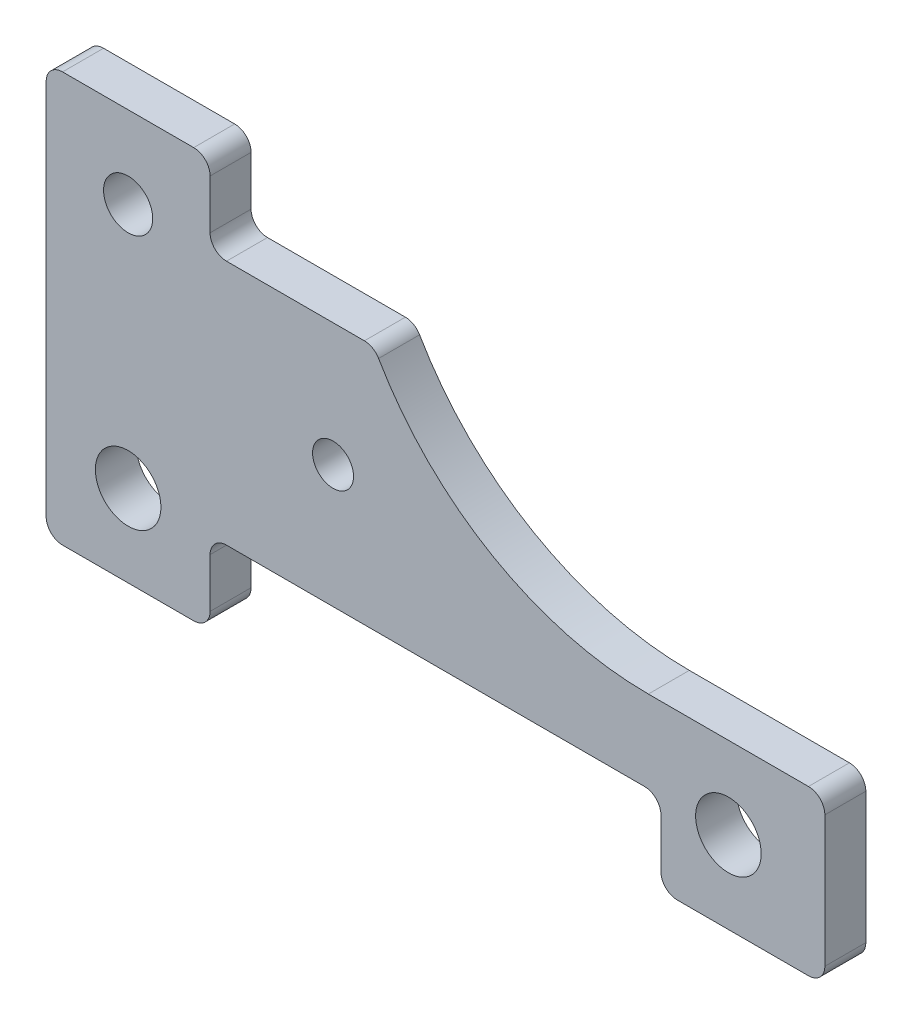
from build123d import *

# Parameters (mm, degrees)
BOSS_EXTRUDE4_DEPTH = 25
SKETCH8_R           = 30
SKETCH8_R_2         = 40
SKETCH8_R_3         = 25
CUT_EXTRUDE2_DEPTH  = 51


with BuildPart() as part:
    # Sketch6 → Boss-Extrude4 (new body, symmetric)
    with BuildSketch(Plane.XY):
        with BuildLine():
            Line((20, 0), (180, 0))
            ThreePointArc((180, 0), (194.142135624, 5.857864376), (200, 20))
            Line((200, 20), (200, 80))
            ThreePointArc((200, 80), (205.857864376, 94.142135624), (220, 100))
            Line((220, 100), (730, 100))
            ThreePointArc((730, 100), (744.142135624, 94.142135624), (750, 80))
            Line((750, 80), (750, 20))
            ThreePointArc((750, 20), (755.857864376, 5.857864376), (770, 0))
            Line((770, 0), (930, 0))
            ThreePointArc((930, 0), (944.142135624, 5.857864376), (950, 20))
            Line((950, 20), (950, 180))
            ThreePointArc((950, 180), (944.142135624, 194.142135624), (930, 200))
            Line((930, 200), (734.664010614, 200))
            ThreePointArc((734.664010614, 200), (544.664010614, 250.910346562), (405.574357176, 390))
            ThreePointArc((405.574357176, 390), (398.2538491, 397.320508076), (388.2538491, 400))
            Line((388.2538491, 400), (220, 400))
            ThreePointArc((220, 400), (205.857864376, 405.857864376), (200, 420))
            Line((200, 420), (200, 480))
            ThreePointArc((200, 480), (194.142135624, 494.142135624), (180, 500))
            Line((180, 500), (20, 500))
            ThreePointArc((20, 500), (5.857864376, 494.142135624), (0, 480))
            Line((0, 480), (0, 20))
            ThreePointArc((0, 20), (5.857864376, 5.857864376), (20, 0))
        make_face()
    extrude(amount=BOSS_EXTRUDE4_DEPTH, both=True)

    # Sketch8 → Cut-Extrude2 (cut, through all)
    with BuildSketch(Plane.XY.offset(25)):
        with Locations((100, 400)):
            Circle(SKETCH8_R)
        with Locations((100, 100)):
            Circle(SKETCH8_R_2)
        with Locations((350, 250)):
            Circle(SKETCH8_R_3)
        with Locations((832.332005307, 100)):
            Circle(SKETCH8_R_2)
    extrude(amount=-CUT_EXTRUDE2_DEPTH, mode=Mode.SUBTRACT)


solid = part.part
